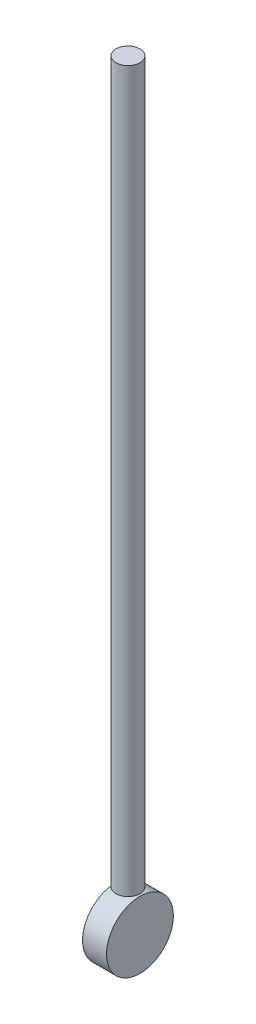
from build123d import *

# Parameters (mm, degrees)
SKETCH1_R           = 6.35
BOSS_EXTRUDE1_DEPTH = 381
SKETCH2_R           = 17.700592194
BOSS_EXTRUDE2_DEPTH = 6.35


with BuildPart() as part:
    # Sketch1 → Boss-Extrude1 (new body)
    with BuildSketch(Plane(origin=(0, 0, 0), x_dir=(1, 0, 0), z_dir=(0, 1, 0))):
        Circle(SKETCH1_R)
    extrude(amount=BOSS_EXTRUDE1_DEPTH)


with BuildPart() as body_2:
    # Sketch2 → Boss-Extrude2 (new body, symmetric)
    with BuildSketch(Plane(origin=(0, 0, 0), x_dir=(0, 0, -1), z_dir=(1, 0, 0))):
        with Locations((0, -18.863838614)):
            Circle(SKETCH2_R)
    extrude(amount=BOSS_EXTRUDE2_DEPTH, both=True)


solid = Compound([part.part, body_2.part])
